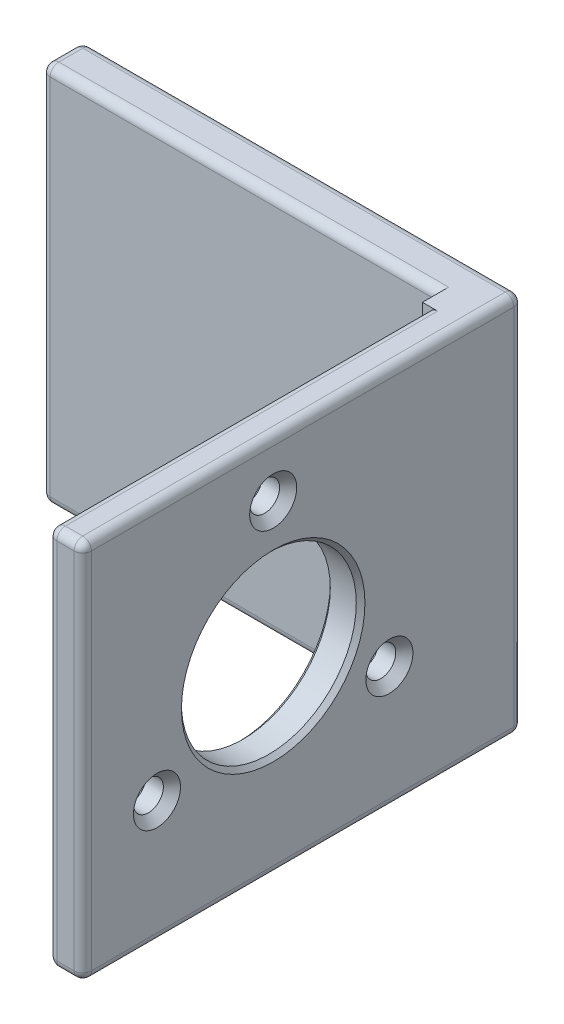
from build123d import *

# Parameters (mm, degrees)
EXTRUDE_THIN2_DEPTH            = 22
SKETCH3_W                      = 44
SKETCH3_H                      = 44
CUT_EXTRUDE1_DEPTH             = 0.7625
SKETCH4_R                      = 10.1
CUT_EXTRUDE2_DEPTH             = 5
F_8_32_TAPPED_HOLE1_AT_2_COUNT = 2
F_8_32_TAPPED_HOLE1_AT_2_PITCH = 26.846787517
F_8_32_TAPPED_HOLE1_AT_3_COUNT = 2
F_8_32_TAPPED_HOLE1_AT_3_PITCH = 26.846787517
CHAMFER2_SIZE                  = 0.5
FILLET1_R                      = 1


with BuildPart() as part:
    # Sketch2 → Extrude-Thin2 (new body, symmetric)
    with BuildSketch(Plane(origin=(0, 0, 0), x_dir=(1, 0, 0), z_dir=(0, 1, 0))):
        Polygon((0, -50.8), (0, 0), (-50.8, 0), (-50.8, -4.7625), (-4.7625, -4.7625), (-4.7625, -50.8), align=None)
    extrude(amount=EXTRUDE_THIN2_DEPTH, both=True)

    # Sketch3 → Cut-Extrude1 (cut)
    with BuildSketch(Plane.ZY.offset(4.7625)):
        with Locations((28.8, 0)):
            Rectangle(SKETCH3_W, SKETCH3_H)
    extrude(amount=-CUT_EXTRUDE1_DEPTH, mode=Mode.SUBTRACT)

    # Sketch4 → Cut-Extrude2 (cut, through all)
    with BuildSketch(Plane.ZY.offset(4)):
        with Locations((28.8, 0)):
            Circle(SKETCH4_R)
    extrude(amount=-CUT_EXTRUDE2_DEPTH, mode=Mode.SUBTRACT)

    # Sketch6 → #8-32 Tapped Hole1 (revolve, cut)
    with BuildSketch(Plane(origin=(-4, 15.5, 28.8), x_dir=(0, 0, 1), z_dir=(0, 1, 0))):
        Polygon((0, 0), (0, 4), (2.7178, 4), (1.7272, 3.0094), (1.7272, 0.9906), (2.7178, 0), align=None)
    f_8_32_tapped_hole1 = revolve(axis=Axis((-10.35, 15.5, 28.8), (1, 0, 0)), mode=Mode.SUBTRACT)

    # #8-32 Tapped Hole1 at 2: #8-32 Tapped Hole1 ×2
    with Locations(*[Vector(0, -0.866025404, 0.5) * (i * F_8_32_TAPPED_HOLE1_AT_2_PITCH) for i in range(1, F_8_32_TAPPED_HOLE1_AT_2_COUNT)]):
        add(f_8_32_tapped_hole1, mode=Mode.SUBTRACT)

    # #8-32 Tapped Hole1 at 3: #8-32 Tapped Hole1 ×2
    with Locations(*[Vector(0, -0.866025404, -0.5) * (i * F_8_32_TAPPED_HOLE1_AT_3_PITCH) for i in range(1, F_8_32_TAPPED_HOLE1_AT_3_COUNT)]):
        add(f_8_32_tapped_hole1, mode=Mode.SUBTRACT)

    # Chamfer2
    chamfer2_edges = [part.edges().sort_by_distance(p)[0] for p in [
        (0, 0, 18.7),
        (-4, 0, 18.7),
    ]]
    chamfer(chamfer2_edges, length=CHAMFER2_SIZE)

    # Fillet1
    fillet1_edges = [part.edges().sort_by_distance(p)[0] for p in [
        (0, 22, 25.4),
        (-25.4, 22, 0),
        (-50.8, 22, 2.38125),
        (-27.78125, 22, 4.7625),
        (-4, -22, 28.8),
        (-4, 0, 50.8),
        (-4, 22, 28.8),
        (-27.78125, -22, 4.7625),
        (-50.8, -22, 2.38125),
        (-25.4, -22, 0),
        (0, -22, 25.4),
        (-2, -22, 50.8),
        (-2, 22, 50.8),
        (-50.8, 0, 4.7625),
        (-50.8, 0, 0),
        (0, 0, 0),
        (0, 0, 50.8),
    ]]
    fillet(fillet1_edges, radius=FILLET1_R)


solid = part.part
